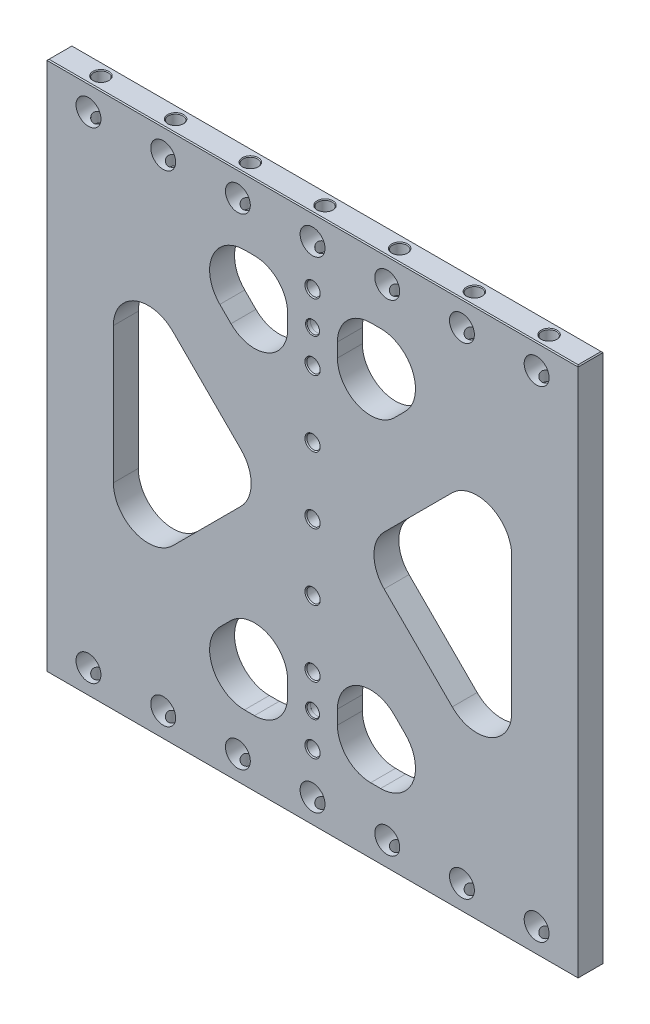
from build123d import *

# Parameters (mm, degrees)
SKETCH2_W                                = 406.4
SKETCH2_H                                = 406.4
EXTRUDE1_DEPTH                           = 9.525
TRIANGLES_CUT_EXTRUDE2_DEPTH             = 20.05
TRIANGLES_FILLET1_R                      = 26.67
SKETCH14_W                               = 38.1
SKETCH14_H                               = 406.4
EXTRUDE5_DEPTH                           = 19.05
FILLET3_R                                = 25.4
LPATTERN5_COUNT                          = 4
LPATTERN5_PITCH                          = 50.8
LPATTERN5_COL_COUNT                      = 4
LPATTERN5_COL_PITCH                      = 50.8
F_3_4_0_75_DIAMETER_HOLE1_D              = 19.05
LPATTERN4_COUNT                          = 4
LPATTERN4_PITCH                          = 57.15
LPATTERN4_COL_COUNT                      = 4
LPATTERN4_COL_PITCH                      = 57.15
MIRROR2_COPY_1_D                         = 19.05
MIRROR2_COPY_2_D                         = 19.05
MIRROR2_COPY_3_D                         = 19.05
MIRROR2_COPY_7_D                         = 19.05
MIRROR2_COPY_8_D                         = 19.05
MIRROR2_COPY_9_D                         = 19.05
F_3_8_0_375_PIN_LEAD_IN_HOLE1_AT_2_COUNT = 2
F_3_8_0_375_PIN_LEAD_IN_HOLE1_AT_2_PITCH = 254
CHAMFER1_SIZE                            = 0.762


with BuildPart() as part:
    # Sketch2 → Extrude1 (new body, symmetric)
    with BuildSketch(Plane.XY):
        Rectangle(SKETCH2_W, SKETCH2_H)
    extrude(amount=EXTRUDE1_DEPTH, both=True)

    # Sketch8 → Triangles -- Cut-Extrude2 (cut, through all)
    with BuildSketch(Plane.XY.offset(9.525)):
        Polygon((-152.4, 116.478975516), (-35.921024484, 0), (-152.4, -116.478975516), align=None)
        Polygon((-116.478975516, 152.4), (0, 35.921024484), (116.478975516, 152.4), align=None)
        Polygon((152.4, 116.478975516), (152.4, -116.478975516), (35.921024484, 0), align=None)
        Polygon((0, -35.921024484), (-116.478975516, -152.4), (116.478975516, -152.4), align=None)
    extrude(amount=-TRIANGLES_CUT_EXTRUDE2_DEPTH, mode=Mode.SUBTRACT)

    # Triangles -- Fillet1
    triangles_fillet1_edges = [part.edges().sort_by_distance(p)[0] for p in [
        (-152.4, -116.478975516, 0),
        (-152.4, 116.478975516, 0),
        (-35.921024484, 0, 0),
        (-116.478975516, 152.4, 0),
        (116.478975516, 152.4, 0),
        (35.921024484, 0, 0),
        (152.4, 116.478975516, 0),
        (152.4, -116.478975516, 0),
        (116.478975516, -152.4, 0),
        (-116.478975516, -152.4, 0),
    ]]
    fillet(triangles_fillet1_edges, radius=TRIANGLES_FILLET1_R)

    # Sketch14 → Extrude5 (add, through all)
    with BuildSketch(Plane.XY.offset(9.525)):
        Rectangle(SKETCH14_W, SKETCH14_H)
    extrude(amount=-EXTRUDE5_DEPTH)

    # Fillet3
    fillet3_edges = [part.edges().sort_by_distance(p)[0] for p in [
        (-19.05, -54.971024484, 0),
        (19.05, -152.4, 0),
        (19.05, 152.4, 0),
        (19.05, 54.971024484, 0),
        (19.05, -54.971024484, 0),
        (-19.05, 152.4, 0),
        (-19.05, -152.4, 0),
        (-19.05, 54.971024484, 0),
    ]]
    fillet(fillet3_edges, radius=FILLET3_R)

    # Sketch15 → CBORE for 3/8 Socket Head Cap Screw1 (revolve, cut)
    with BuildSketch(Plane(origin=(0, 0, -9.525), x_dir=(0, 1, 0), z_dir=(1, 0, 0))):
        Polygon((0, 0), (0, 19.05), (5.842, 19.05), (5.15874, 18.263999282), (5.15874, 4.318), (8.73125, 4.318), (8.73125, 0), align=None)
    cbore_for_3_8_socket_head_cap_screw1 = revolve(axis=Axis((0, 0, -15.875), (0, 0, 1)), mode=Mode.SUBTRACT)

    # LPattern5: CBORE for 3/8 Socket Head Cap Screw1 ×4
    with Locations(*[(0, i * LPATTERN5_PITCH, 0) for i in range(1, LPATTERN5_COUNT)]):
        add(cbore_for_3_8_socket_head_cap_screw1, mode=Mode.SUBTRACT)

    # LPattern5 col: CBORE for 3/8 Socket Head Cap Screw1 ×4
    with Locations(*[(0, -i * LPATTERN5_COL_PITCH, 0) for i in range(1, LPATTERN5_COL_COUNT)]):
        add(cbore_for_3_8_socket_head_cap_screw1, mode=Mode.SUBTRACT)

    # 3/4 (0.75) Diameter Hole1 (through all)
    with Locations(Plane.XY.offset(9.525)):
        with Locations((0, -184.15)):
            f_3_4_0_75_diameter_hole1 = Hole(F_3_4_0_75_DIAMETER_HOLE1_D / 2)

    # Sketch12 → 7/16 (0.4375) Diameter Hole1 (revolve, cut)
    with BuildSketch(Plane(origin=(0, -203.2, 0), x_dir=(0, 0, -1), z_dir=(1, 0, 0))):
        Polygon((0, 0), (0, 38.263531814), (5.55625, 34.925), (5.55625, 0.620911348), (6.096, 0), align=None)
    f_7_16_0_4375_diameter_hole1 = revolve(axis=Axis((0, -209.55, 0), (0, 1, 0)), mode=Mode.SUBTRACT)

    # LPattern4: 3/4 (0.75) Diameter Hole1, 7/16 (0.4375) Diameter Hole1 ×4
    with Locations(*[(i * LPATTERN4_PITCH, 0, 0) for i in range(1, LPATTERN4_COUNT)]):
        add(f_3_4_0_75_diameter_hole1, mode=Mode.SUBTRACT)
        add(f_7_16_0_4375_diameter_hole1, mode=Mode.SUBTRACT)

    # LPattern4 col: 3/4 (0.75) Diameter Hole1, 7/16 (0.4375) Diameter Hole1 ×4
    with Locations(*[(-i * LPATTERN4_COL_PITCH, 0, 0) for i in range(1, LPATTERN4_COL_COUNT)]):
        add(f_3_4_0_75_diameter_hole1, mode=Mode.SUBTRACT)
        add(f_7_16_0_4375_diameter_hole1, mode=Mode.SUBTRACT)

    # Mirror2: 3/4 (0.75) Diameter Hole1, 7/16 (0.4375) Diameter Hole1 across plane
    add(f_3_4_0_75_diameter_hole1.mirror(Plane.ZX), mode=Mode.SUBTRACT)
    add(f_7_16_0_4375_diameter_hole1.mirror(Plane.ZX), mode=Mode.SUBTRACT)

    # Mirror2 copy 1 (through all)
    with Locations(Plane(origin=(57.15, 0, 9.525), x_dir=(1, 0, 0), z_dir=(0, 0, 1))):
        with Locations((0, 184.15)):
            Hole(MIRROR2_COPY_1_D / 2)

    # Mirror2 copy 2 (through all)
    with Locations(Plane(origin=(114.3, 0, 9.525), x_dir=(1, 0, 0), z_dir=(0, 0, 1))):
        with Locations((0, 184.15)):
            Hole(MIRROR2_COPY_2_D / 2)

    # Mirror2 copy 3 (through all)
    with Locations(Plane(origin=(171.45, 0, 9.525), x_dir=(1, 0, 0), z_dir=(0, 0, 1))):
        with Locations((0, 184.15)):
            Hole(MIRROR2_COPY_3_D / 2)

    # Mirror2 copy 4 sketch → Mirror2 copy 4 (revolve, cut)
    with BuildSketch(Plane(origin=(57.15, 203.2, 0), x_dir=(0, 0, -1), z_dir=(1, 0, 0))):
        Polygon((0, 0), (0, -38.263531814), (5.55625, -34.925), (5.55625, -0.620911348), (6.096, 0), align=None)
    revolve(axis=Axis((57.15, 209.55, 0), (0, 1, 0)), mode=Mode.SUBTRACT)

    # Mirror2 copy 5 sketch → Mirror2 copy 5 (revolve, cut)
    with BuildSketch(Plane(origin=(114.3, 203.2, 0), x_dir=(0, 0, -1), z_dir=(1, 0, 0))):
        Polygon((0, 0), (0, -38.263531814), (5.55625, -34.925), (5.55625, -0.620911348), (6.096, 0), align=None)
    revolve(axis=Axis((114.3, 209.55, 0), (0, 1, 0)), mode=Mode.SUBTRACT)

    # Mirror2 copy 6 sketch → Mirror2 copy 6 (revolve, cut)
    with BuildSketch(Plane(origin=(171.45, 203.2, 0), x_dir=(0, 0, -1), z_dir=(1, 0, 0))):
        Polygon((0, 0), (0, -38.263531814), (5.55625, -34.925), (5.55625, -0.620911348), (6.096, 0), align=None)
    revolve(axis=Axis((171.45, 209.55, 0), (0, 1, 0)), mode=Mode.SUBTRACT)

    # Mirror2 copy 7 (through all)
    with Locations(Plane(origin=(-57.15, 0, 9.525), x_dir=(1, 0, 0), z_dir=(0, 0, 1))):
        with Locations((0, 184.15)):
            Hole(MIRROR2_COPY_7_D / 2)

    # Mirror2 copy 8 (through all)
    with Locations(Plane(origin=(-114.3, 0, 9.525), x_dir=(1, 0, 0), z_dir=(0, 0, 1))):
        with Locations((0, 184.15)):
            Hole(MIRROR2_COPY_8_D / 2)

    # Mirror2 copy 9 (through all)
    with Locations(Plane(origin=(-171.45, 0, 9.525), x_dir=(1, 0, 0), z_dir=(0, 0, 1))):
        with Locations((0, 184.15)):
            Hole(MIRROR2_COPY_9_D / 2)

    # Mirror2 copy 10 sketch → Mirror2 copy 10 (revolve, cut)
    with BuildSketch(Plane(origin=(-57.15, 203.2, 0), x_dir=(0, 0, -1), z_dir=(1, 0, 0))):
        Polygon((0, 0), (0, -38.263531814), (5.55625, -34.925), (5.55625, -0.620911348), (6.096, 0), align=None)
    revolve(axis=Axis((-57.15, 209.55, 0), (0, 1, 0)), mode=Mode.SUBTRACT)

    # Mirror2 copy 11 sketch → Mirror2 copy 11 (revolve, cut)
    with BuildSketch(Plane(origin=(-114.3, 203.2, 0), x_dir=(0, 0, -1), z_dir=(1, 0, 0))):
        Polygon((0, 0), (0, -38.263531814), (5.55625, -34.925), (5.55625, -0.620911348), (6.096, 0), align=None)
    revolve(axis=Axis((-114.3, 209.55, 0), (0, 1, 0)), mode=Mode.SUBTRACT)

    # Mirror2 copy 12 sketch → Mirror2 copy 12 (revolve, cut)
    with BuildSketch(Plane(origin=(-171.45, 203.2, 0), x_dir=(0, 0, -1), z_dir=(1, 0, 0))):
        Polygon((0, 0), (0, -38.263531814), (5.55625, -34.925), (5.55625, -0.620911348), (6.096, 0), align=None)
    revolve(axis=Axis((-171.45, 209.55, 0), (0, 1, 0)), mode=Mode.SUBTRACT)

    # Sketch17 → 3/8 (0.375) Pin + Lead-In Hole1 (revolve, cut)
    with BuildSketch(Plane(origin=(0, 127, 9.525), x_dir=(0, -1, 0), z_dir=(1, 0, 0))):
        Polygon((0, 0), (0, 19.05), (4.7625, 19.05), (4.7625, 3.175), (4.7879, 3.175), (4.7879, 0.628216187), (5.334, 0), align=None)
    f_3_8_0_375_pin_lead_in_hole1 = revolve(axis=Axis((0, 127, 15.875), (0, 0, -1)), mode=Mode.SUBTRACT)

    # 3/8 (0.375) Pin + Lead-In Hole1 at 2: 3/8 (0.375) Pin + Lead-In Hole1 ×2
    with Locations(*[(0, -i * F_3_8_0_375_PIN_LEAD_IN_HOLE1_AT_2_PITCH, 0) for i in range(1, F_3_8_0_375_PIN_LEAD_IN_HOLE1_AT_2_COUNT)]):
        add(f_3_8_0_375_pin_lead_in_hole1, mode=Mode.SUBTRACT)

    # Chamfer1
    chamfer1_edges = [part.edges().sort_by_distance(p)[0] for p in [
        (0, 203.2, 9.525),
        (0, 203.2, -9.525),
        (0, -203.2, -9.525),
        (0, -203.2, 9.525),
        (-203.2, 203.2, 0),
        (203.2, 203.2, 0),
        (203.2, -203.2, 0),
        (-203.2, -203.2, 0),
    ]]
    chamfer(chamfer1_edges, length=CHAMFER1_SIZE)


solid = part.part
